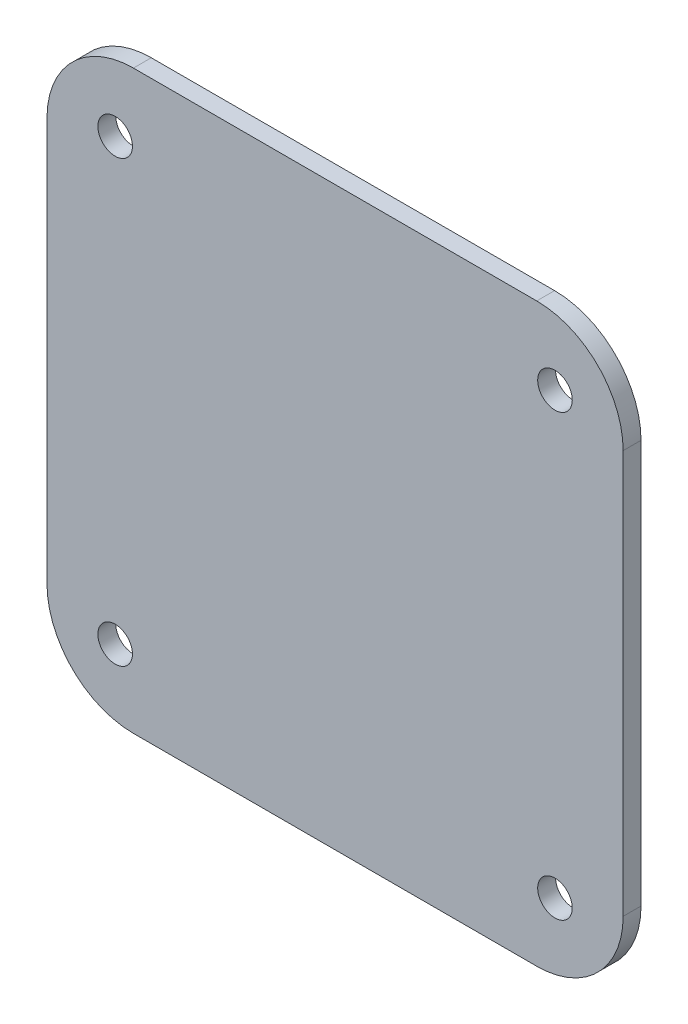
from build123d import *

# Parameters (mm, degrees)
SKETCH1_W           = 100
SKETCH1_H           = 100
SKETCH1_R           = 3
BOSS_EXTRUDE2_DEPTH = 3.1
FILLET1_R           = 15


with BuildPart() as part:
    # Sketch1 → Boss-Extrude2 (new body)
    with BuildSketch(Plane.XY):
        Rectangle(SKETCH1_W, SKETCH1_H)
        with Locations((-38.166088515, 38.166088515)):
            Circle(SKETCH1_R, mode=Mode.SUBTRACT)
        with Locations((38.166088515, 38.166088515)):
            Circle(SKETCH1_R, mode=Mode.SUBTRACT)
        with Locations((38.166088515, -38.166088515)):
            Circle(SKETCH1_R, mode=Mode.SUBTRACT)
        with Locations((-38.166088515, -38.166088515)):
            Circle(SKETCH1_R, mode=Mode.SUBTRACT)
    extrude(amount=BOSS_EXTRUDE2_DEPTH)

    # Fillet1
    fillet1_edges = [part.edges().sort_by_distance(p)[0] for p in [
        (50, -50, 1.55),
        (-50, -50, 1.55),
        (-50, 50, 1.55),
        (50, 50, 1.55),
    ]]
    fillet(fillet1_edges, radius=FILLET1_R)


solid = part.part
